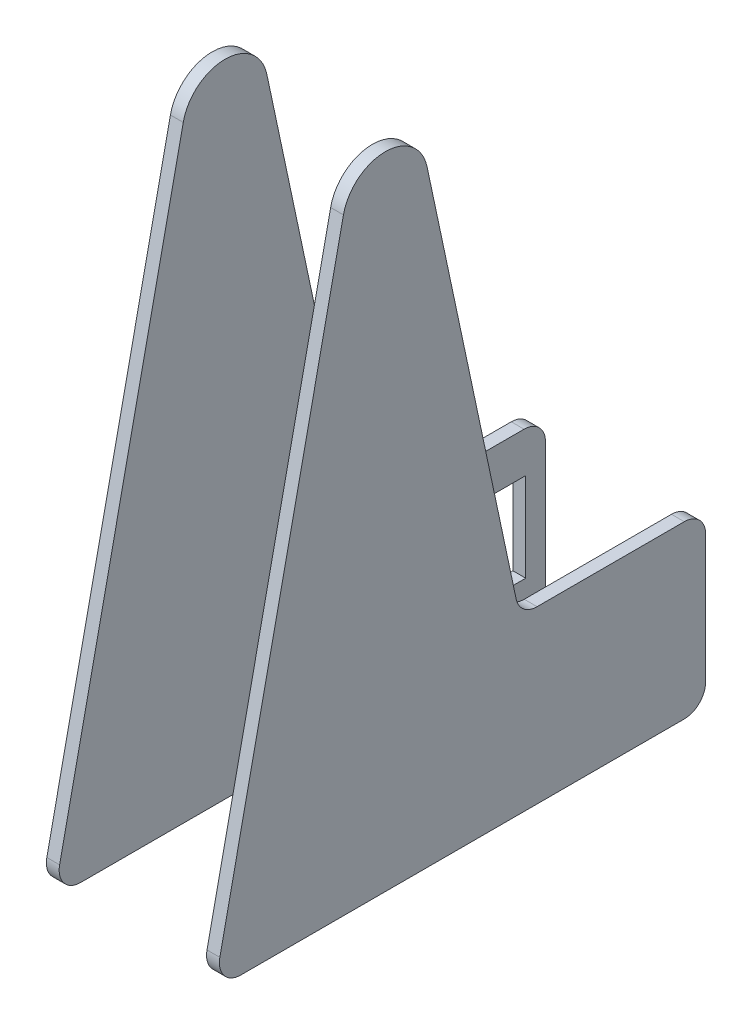
from build123d import *

# Parameters (mm, degrees)
BOSS_EXTRUDE1_DEPTH     = 3
SKETCH5_W               = 41.17320508
SKETCH5_H               = 20.8
CUT_EXTRUDE1_DEPTH      = 1
CUT_EXTRUDE1_DEPTH_BACK = 3


with BuildPart() as part:
    # Sketch3 → Boss-Extrude1 (new body)
    with BuildSketch(Plane(origin=(17.25, 0, 0), x_dir=(0, 0, -1), z_dir=(1, 0, 0))):
        with BuildLine():
            ThreePointArc((-9.781214465, 142.08034699), (0, 150), (9.781214465, 142.08034699))
            Line((9.781214465, 142.08034699), (30.650272205, 43.959826505))
            ThreePointArc((30.650272205, 43.959826505), (32.394521819, 41.114072345), (35.540879438, 40))
            Line((35.540879438, 40), (70, 40))
            ThreePointArc((70, 40), (73.535533906, 38.535533906), (75, 35))
            Line((75, 35), (75, 5))
            ThreePointArc((75, 5), (73.535533906, 1.464466094), (70, 0))
            Line((70, 0), (0, 0))
            Line((0, 0), (-33.824720318, 0))
            ThreePointArc((-33.824720318, 0), (-37.710647973, 1.853642382), (-38.71532755, 6.040173495))
            Line((-38.71532755, 6.040173495), (-9.781214465, 142.08034699))
        make_face()
    extrude(amount=BOSS_EXTRUDE1_DEPTH)


with BuildPart() as body_2:
    # Mirror2: mirrored copy
    add(part.part.mirror(Plane(origin=(0, 0, 0), x_dir=(0, 0, 1), z_dir=(1, 0, 0))))

    # Sketch5 → Cut-Extrude1 (cut, two sides)
    with BuildSketch(Plane.ZY.offset(20.25)) as cut_extrude1_sk:
        with Locations((-49.8, 20)):
            Rectangle(SKETCH5_W, SKETCH5_H)
    extrude(amount=CUT_EXTRUDE1_DEPTH, mode=Mode.SUBTRACT)
    extrude(cut_extrude1_sk.sketch, amount=-CUT_EXTRUDE1_DEPTH_BACK, mode=Mode.SUBTRACT)


solid = Compound([part.part, body_2.part])
